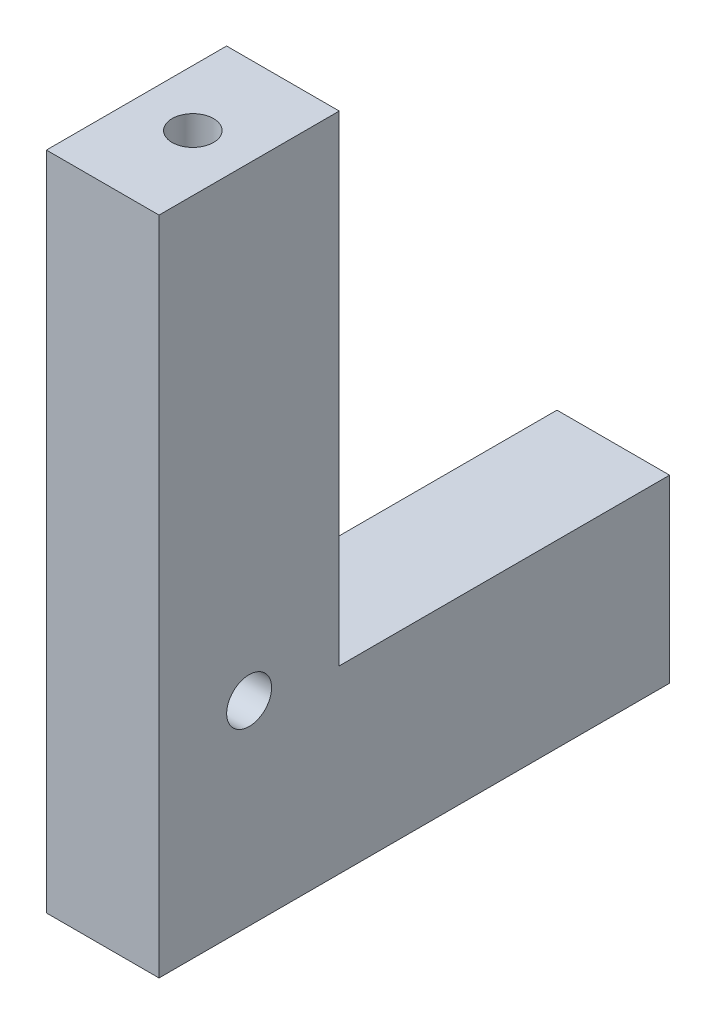
from build123d import *

# Parameters (mm, degrees)
SKETCH1_W                       = 9.525
SKETCH1_H                       = 15.24
EXTRUDE1_DEPTH                  = 43.18
SKETCH4_W                       = 9.525
SKETCH4_H                       = 15.24
EXTRUDE2_DEPTH                  = 40.64
F_6_32_TAPPED_HOLE1_D           = 2.7051
F_6_32_TAPPED_HOLE1_DEPTH       = 13.97
F_6_32_TAPPED_HOLE1_CBORE_D     = 3.5052
F_6_32_TAPPED_HOLE1_CBORE_DEPTH = 9.906
F_6_32_TAPPED_HOLE1_TIP         = 0.81269403
F_6_CLEARANCE_HOLE1_D           = 3.7973
F_6_CLEARANCE_HOLE1_DEPTH       = 9.906
F_6_CLEARANCE_HOLE1_TIP         = 1.140824014
F_6_32_TAPPED_HOLE2_D           = 2.7051
F_6_32_TAPPED_HOLE2_DEPTH       = 13.97
F_6_32_TAPPED_HOLE2_CBORE_D     = 3.5052
F_6_32_TAPPED_HOLE2_CBORE_DEPTH = 9.906
F_6_32_TAPPED_HOLE2_TIP         = 0.81269403


with BuildPart() as part:
    # Sketch1 → Extrude1 (new body)
    with BuildSketch(Plane.XY):
        with Locations((-4.7625, 7.62)):
            Rectangle(SKETCH1_W, SKETCH1_H)
    extrude(amount=EXTRUDE1_DEPTH)

    # Sketch4 → Extrude2 (add)
    with BuildSketch(Plane(origin=(0, 15.24, 0), x_dir=(-1, 0, 0), z_dir=(0, 1, 0))):
        with Locations((4.7625, 35.56)):
            Rectangle(SKETCH4_W, SKETCH4_H)
    extrude(amount=EXTRUDE2_DEPTH)

    # #6-32 Tapped Hole1
    with Locations(Plane(origin=(-4.7625, 11.43, 0), x_dir=(-1, 0, 0), z_dir=(0, 0, -1))):
        with Locations((0, 0), (0, -7.62), (15.003961831, 4.683879058)):
            CounterBoreHole(F_6_32_TAPPED_HOLE1_D / 2, F_6_32_TAPPED_HOLE1_CBORE_D / 2, F_6_32_TAPPED_HOLE1_CBORE_DEPTH, depth=F_6_32_TAPPED_HOLE1_DEPTH)
            with Locations((0, 0, -(F_6_32_TAPPED_HOLE1_DEPTH + F_6_32_TAPPED_HOLE1_TIP / 2))):  # 118° drill point
                Cone(0, F_6_32_TAPPED_HOLE1_D / 2, F_6_32_TAPPED_HOLE1_TIP, mode=Mode.SUBTRACT)

    # #6 Clearance Hole1
    with Locations(Plane(origin=(0, 16.51, 35.56), x_dir=(0, 1, 0), z_dir=(1, 0, 0))):
        with Locations((0, 0)):
            Hole(F_6_CLEARANCE_HOLE1_D / 2, depth=F_6_CLEARANCE_HOLE1_DEPTH)
            with Locations((0, 0, -(F_6_CLEARANCE_HOLE1_DEPTH + F_6_CLEARANCE_HOLE1_TIP / 2))):  # 118° drill point
                Cone(0, F_6_CLEARANCE_HOLE1_D / 2, F_6_CLEARANCE_HOLE1_TIP, mode=Mode.SUBTRACT)

    # #6-32 Tapped Hole2
    with Locations(Plane(origin=(-4.7625, 55.88, 35.56), x_dir=(1, 0, 0), z_dir=(0, 1, 0))):
        with Locations((0, 0)):
            CounterBoreHole(F_6_32_TAPPED_HOLE2_D / 2, F_6_32_TAPPED_HOLE2_CBORE_D / 2, F_6_32_TAPPED_HOLE2_CBORE_DEPTH, depth=F_6_32_TAPPED_HOLE2_DEPTH)
            with Locations((0, 0, -(F_6_32_TAPPED_HOLE2_DEPTH + F_6_32_TAPPED_HOLE2_TIP / 2))):  # 118° drill point
                Cone(0, F_6_32_TAPPED_HOLE2_D / 2, F_6_32_TAPPED_HOLE2_TIP, mode=Mode.SUBTRACT)


solid = part.part
